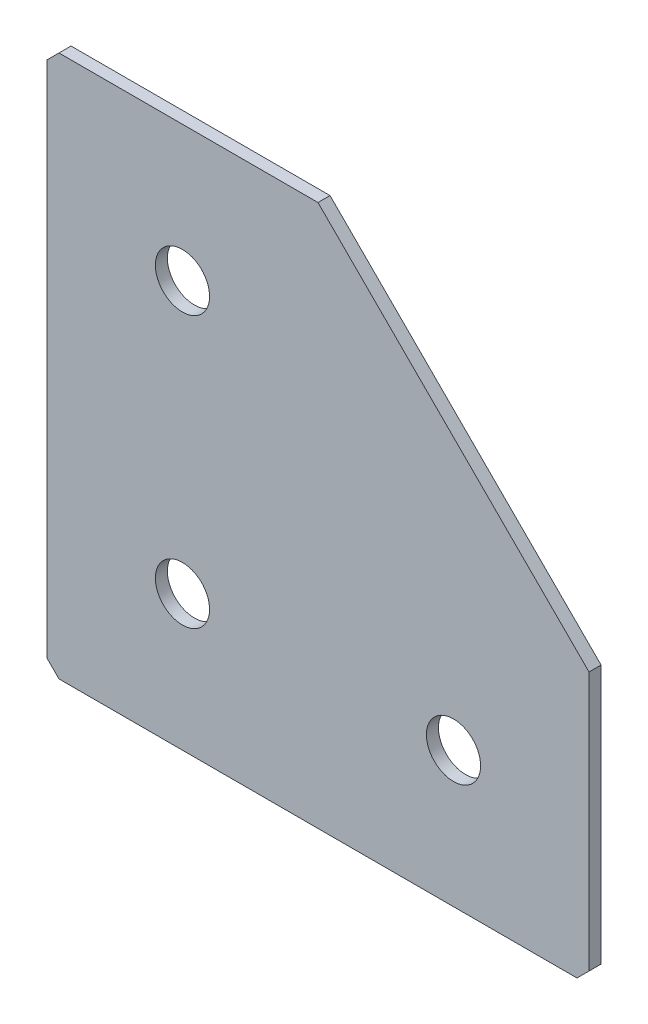
from build123d import *

# Parameters (mm, degrees)
EXTRUDE_1_DEPTH   = 2
HOLE_WIZARD_M81_D = 9
CHAMFER_1_SIZE    = 2


with BuildPart() as part:
    # Эскиз1 → Бобышка-Вытянуть1 (new body)
    with BuildSketch(Plane(origin=(0, 0, 0), x_dir=(1, 0, 0), z_dir=(0, 0, -1))):
        Polygon((0, 0), (0, 90), (90, 90), (90, 45), (45, 0), align=None)
    extrude(amount=EXTRUDE_1_DEPTH)

    # Отверстие с зазором M81 (through all)
    with Locations(Plane(origin=(0, 0, -2), x_dir=(1, 0, 0), z_dir=(0, 0, -1))):
        with Locations((22.5, 67.5), (22.5, 22.5), (67.5, 67.5)):
            Hole(HOLE_WIZARD_M81_D / 2)

    # Фаска1
    chamfer_1_edges = [part.edges().sort_by_distance(p)[0] for p in [
        (0, 0, -1),
        (0, -90, -1),
        (90, -90, -1),
    ]]
    chamfer(chamfer_1_edges, length=CHAMFER_1_SIZE)


solid = part.part
